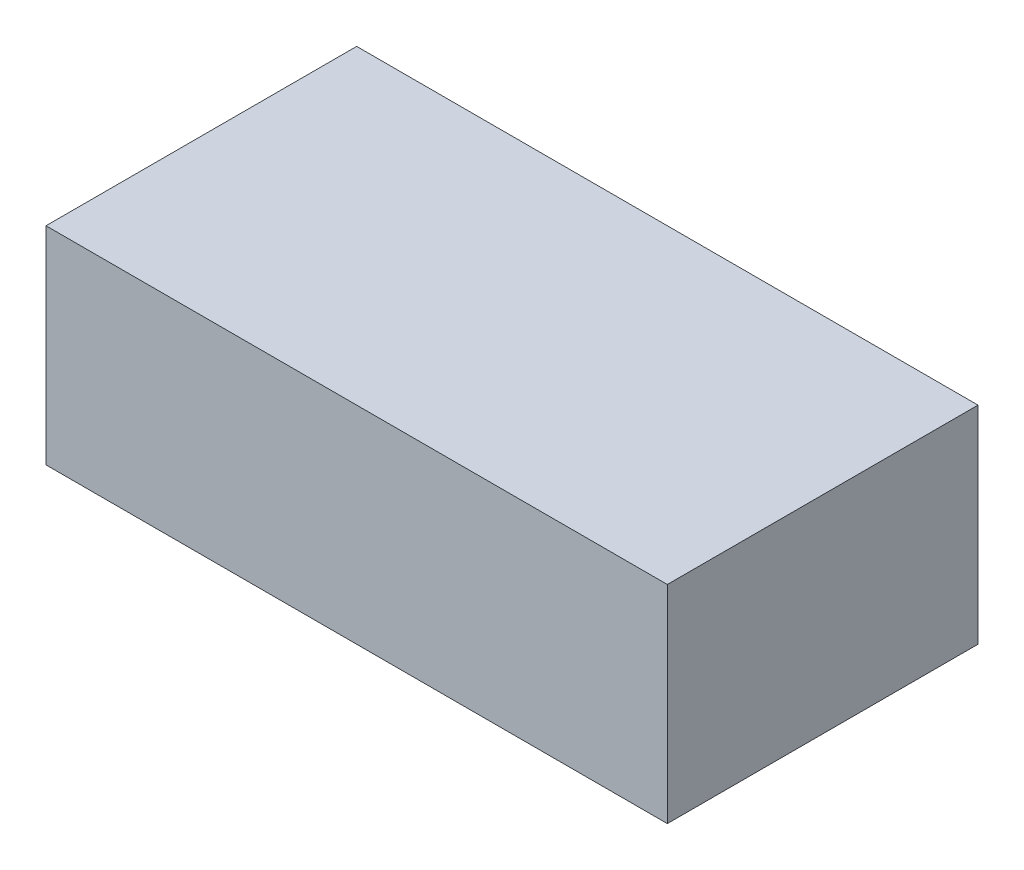
from build123d import *

# Parameters (mm, degrees)
SKETCH1_W           = 60
SKETCH1_H           = 30
BOSS_EXTRUDE1_DEPTH = 20


with BuildPart() as part:
    # Sketch1 → Boss-Extrude1 (new body)
    with BuildSketch(Plane(origin=(0, 0, 0), x_dir=(1, 0, 0), z_dir=(0, 1, 0))):
        Rectangle(SKETCH1_W, SKETCH1_H)
    extrude(amount=BOSS_EXTRUDE1_DEPTH)


solid = part.part
